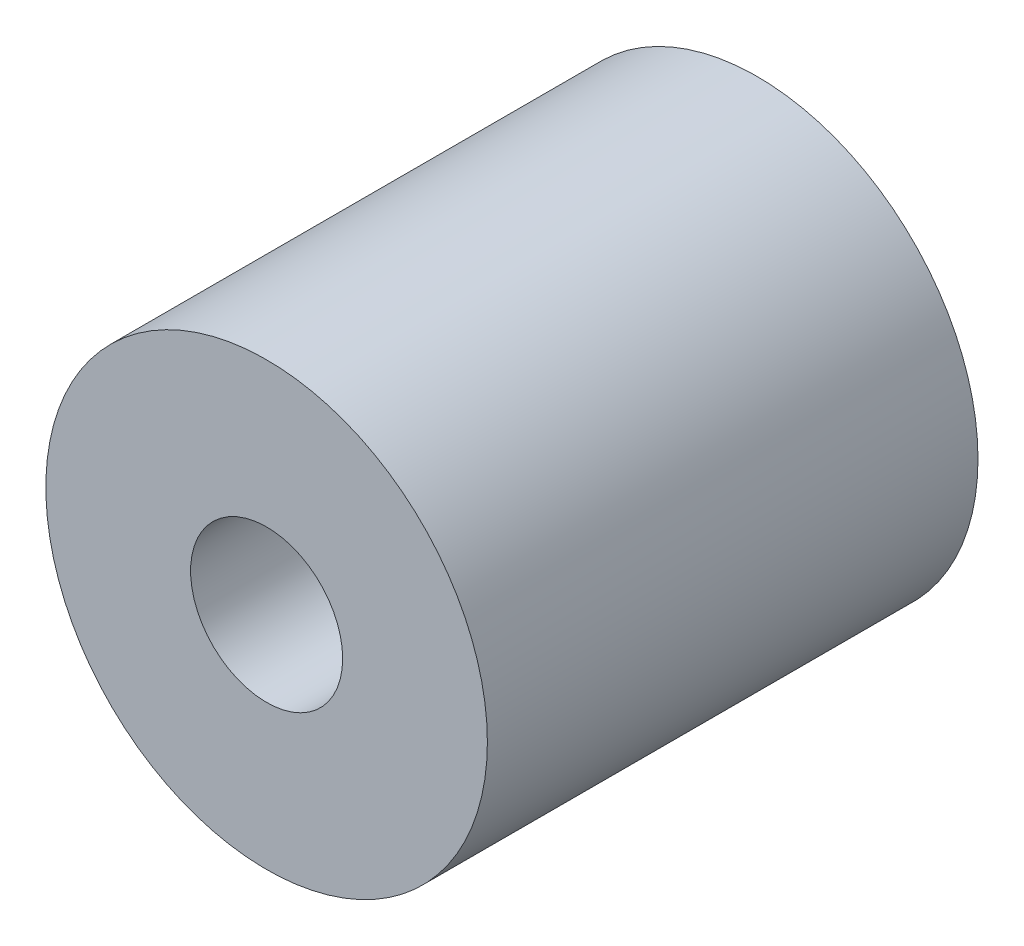
from build123d import *

# Parameters (mm, degrees)
SKETCH1_R           = 4.5
SKETCH1_R_2         = 1.55
BOSS_EXTRUDE1_DEPTH = 10


with BuildPart() as part:
    # Sketch1 → Boss-Extrude1 (new body)
    with BuildSketch(Plane.XY):
        Circle(SKETCH1_R)
        Circle(SKETCH1_R_2, mode=Mode.SUBTRACT)
    extrude(amount=BOSS_EXTRUDE1_DEPTH)


solid = part.part
